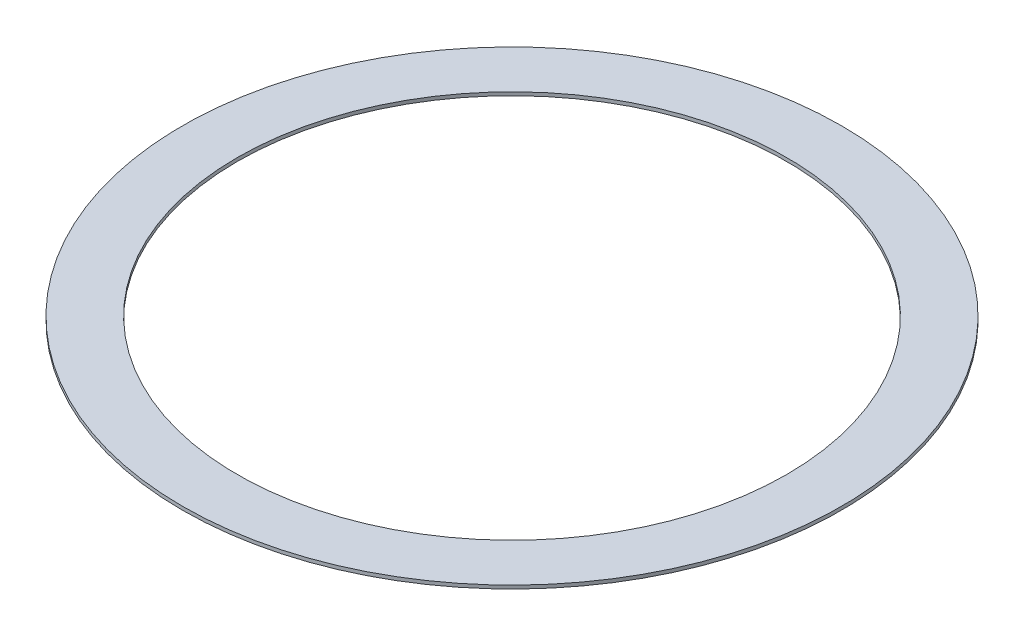
from build123d import *

# Parameters (mm, degrees)
CROQUIS1_R            = 48
CROQUIS1_R_2          = 40
EXTRUIR_L_MINA1_DEPTH = 0.5


with BuildPart() as part:
    # Croquis1 → Extruir-Lámina1 (new body)
    with BuildSketch(Plane(origin=(0, 0, 0), x_dir=(1, 0, 0), z_dir=(0, 1, 0))):
        Circle(CROQUIS1_R)
        Circle(CROQUIS1_R_2, mode=Mode.SUBTRACT)
    extrude(amount=EXTRUIR_L_MINA1_DEPTH)


solid = part.part
